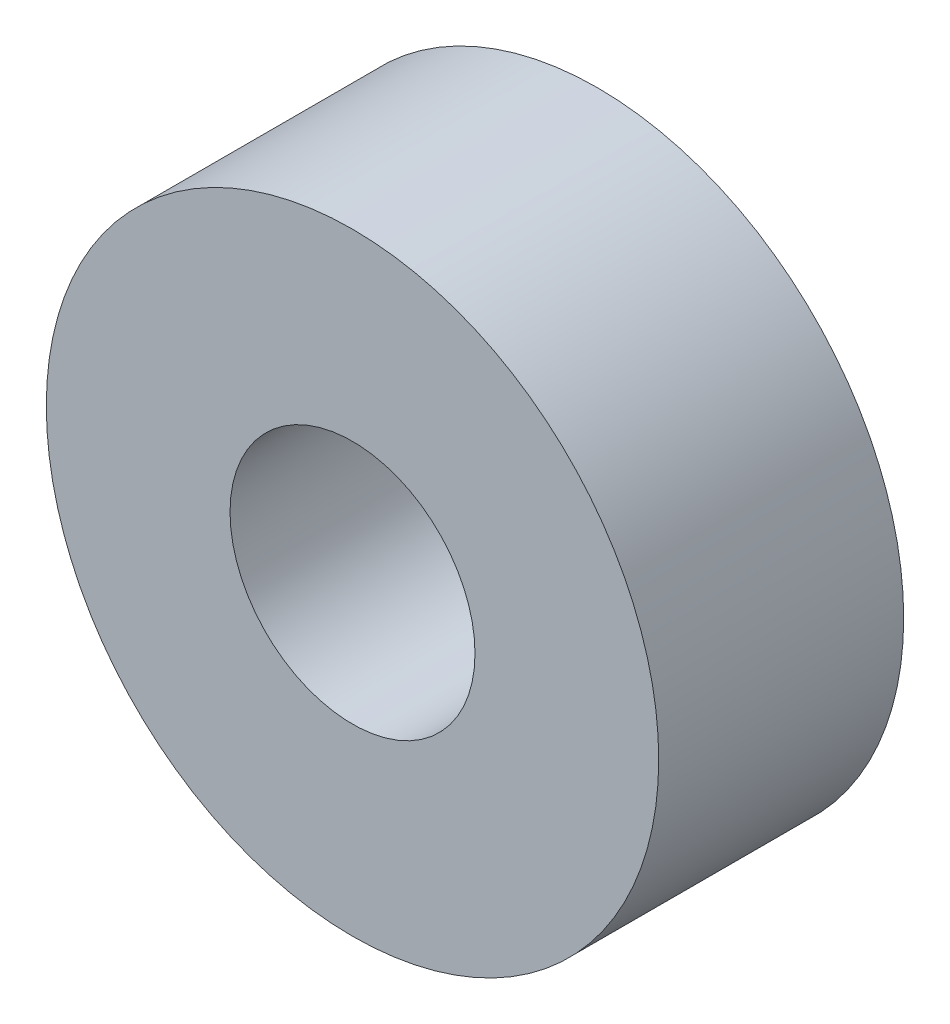
from build123d import *

# Parameters (mm, degrees)
SKETCH_1_R      = 5
SKETCH_1_R_2    = 2
EXTRUDE_1_DEPTH = 4


with BuildPart() as part:
    # 草图1 → 凸台-拉伸1 (new body)
    with BuildSketch(Plane.XY):
        Circle(SKETCH_1_R)
        Circle(SKETCH_1_R_2, mode=Mode.SUBTRACT)
    extrude(amount=EXTRUDE_1_DEPTH)


solid = part.part
